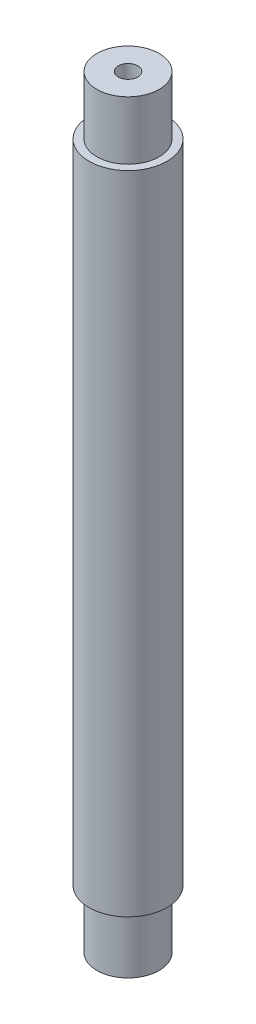
from build123d import *


with BuildPart() as part:
    # Szkic1 → Obrót1 (revolve)
    with BuildSketch(Plane.XY):
        Polygon((0, 18), (0, 0), (8, 0), (8, 15), (10, 15), (10, 181), (8, 181), (8, 196), (2.5, 196), (2.5, 178), (8, 178), (8, 18), align=None)
    revolve(axis=Axis((0, 0, 0), (0, 1, 0)))


solid = part.part
